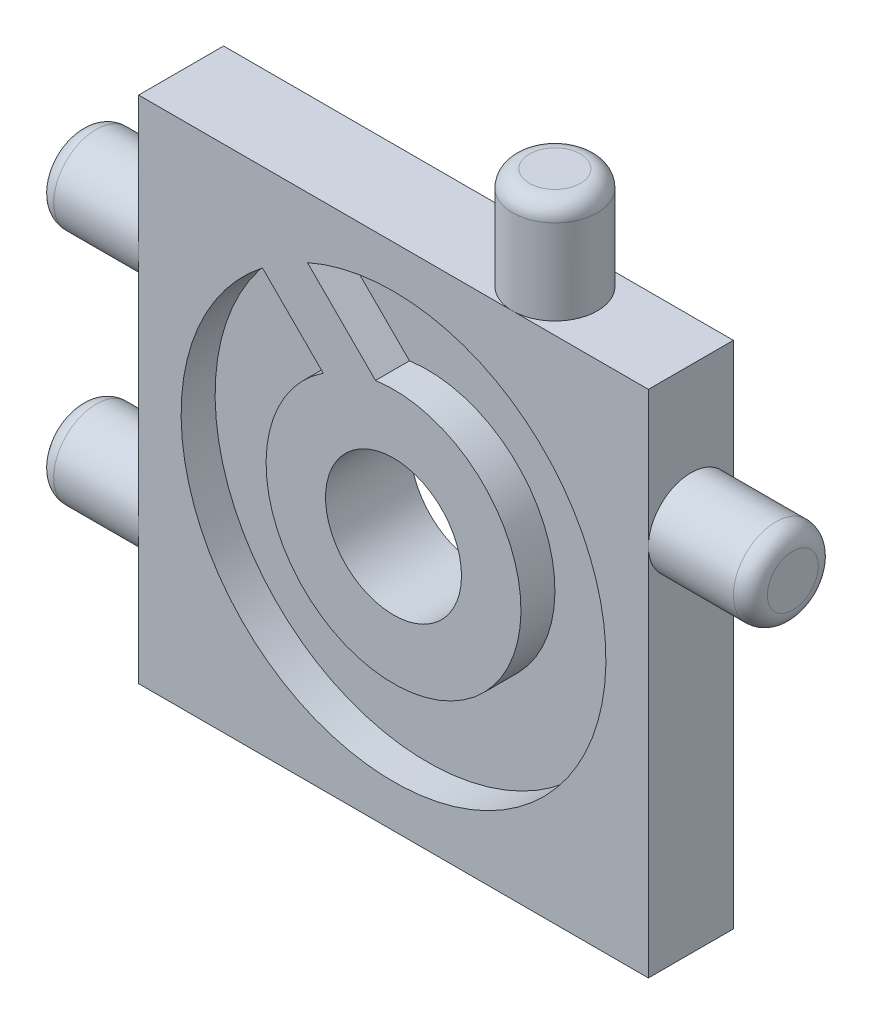
from build123d import *

# Parameters (mm, degrees)
ESQUISSE2_W              = 30
ESQUISSE2_H              = 30
BOSS_EXTRU_1_DEPTH       = 5
ESQUISSE16_R             = 2.5
BOSS_EXTRU_7_DEPTH       = 6
CONG_3_R                 = 1
ESQUISSE18_R             = 2.5
BOSS_EXTRU_9_DEPTH       = 6
CONG_5_R                 = 1
ESQUISSE8_R              = 12.5
ENL_V_MAT_EXTRU_1_DEPTH  = 2
ESQUISSE19_R             = 7.5
BOSS_EXTRU_10_DEPTH      = 2
ESQUISSE33_R             = 4
ENL_V_MAT_EXTRU_3_DEPTH  = 6
ESQUISSE35_R             = 2.5
BOSS_EXTRU_26_DEPTH      = 6
CONG_6_R                 = 1
BOSS_EXTRU_27_DEPTH      = 2
BOSS_EXTRU_27_DEPTH_BACK = 5.5


with BuildPart() as part:
    # Esquisse2 → Boss.-Extru.1 (new body)
    with BuildSketch(Plane.XY):
        Rectangle(ESQUISSE2_W, ESQUISSE2_H)
    extrude(amount=BOSS_EXTRU_1_DEPTH)

    # Esquisse16 → Boss.-Extru.7 (add)
    with BuildSketch(Plane.ZY.offset(15)):
        with Locations((2.5, 7)):
            Circle(ESQUISSE16_R)
        with Locations((2.5, -7)):
            Circle(ESQUISSE16_R)
    extrude(amount=BOSS_EXTRU_7_DEPTH)

    # Congé3
    cong_3_edges = [part.edges().sort_by_distance(p)[0] for p in [
        (-21, 7, 0),
        (-21, -7, 0),
    ]]
    fillet(cong_3_edges, radius=CONG_3_R)

    # Esquisse18 → Boss.-Extru.9 (add)
    with BuildSketch(Plane(origin=(15, 0, 0), x_dir=(0, 0, -1), z_dir=(1, 0, 0))):
        with Locations((-2.5, 7)):
            Circle(ESQUISSE18_R)
    extrude(amount=BOSS_EXTRU_9_DEPTH)

    # Congé5
    cong_5_edges = [part.edges().sort_by_distance(p)[0] for p in [
        (21, 7, 5),
    ]]
    fillet(cong_5_edges, radius=CONG_5_R)

    # Esquisse8 → Enlèv. mat.-Extru.1 (cut)
    with BuildSketch(Plane.XY.offset(5)):
        Circle(ESQUISSE8_R)
    extrude(amount=-ENL_V_MAT_EXTRU_1_DEPTH, mode=Mode.SUBTRACT)

    # Esquisse19 → Boss.-Extru.10 (add)
    with BuildSketch(Plane.XY.offset(3)):
        Circle(ESQUISSE19_R)
    extrude(amount=BOSS_EXTRU_10_DEPTH)

    # Esquisse33 → Enlèv. mat.-Extru.3 (cut, through all)
    with BuildSketch(Plane.XY.offset(5)):
        Circle(ESQUISSE33_R)
    extrude(amount=-ENL_V_MAT_EXTRU_3_DEPTH, mode=Mode.SUBTRACT)

    # Esquisse35 → Boss.-Extru.26 (add)
    with BuildSketch(Plane(origin=(0, 15, 0), x_dir=(1, 0, 0), z_dir=(0, 1, 0))):
        with Locations((7, -2.5)):
            Circle(ESQUISSE35_R)
    extrude(amount=BOSS_EXTRU_26_DEPTH)

    # Congé6
    cong_6_edges = [part.edges().sort_by_distance(p)[0] for p in [
        (4.5, 21, 2.5),
    ]]
    fillet(cong_6_edges, radius=CONG_6_R)

    # Esquisse31 → Boss.-Extru.27 (add, two sides)
    with BuildSketch(Plane.XY.offset(3)) as boss_extru_27_sk:
        Polygon((-8.131727984, 10.253048327), (-6.01040764, 12.374368671), (-1.060660172, 7.424621202), (-3.181980515, 5.303300859), align=None)
    extrude(amount=BOSS_EXTRU_27_DEPTH)
    extrude(boss_extru_27_sk.sketch, amount=-BOSS_EXTRU_27_DEPTH_BACK)


solid = part.part
